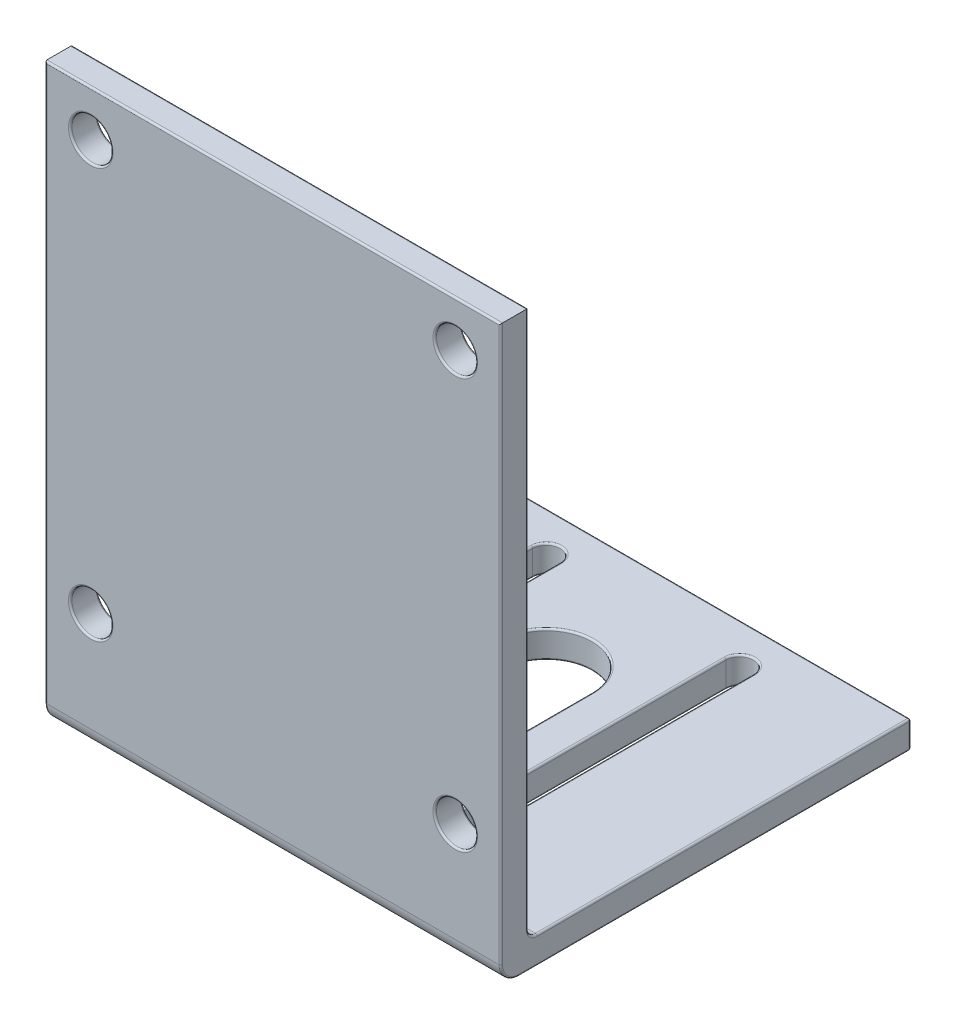
from build123d import *

# Parameters (mm, degrees)
SKETCH1_W           = 50
SKETCH1_H           = 45
BOSS_EXTRUDE1_DEPTH = 3
SKETCH2_W           = 50
SKETCH2_H           = 3
BOSS_EXTRUDE2_DEPTH = 60
SKETCH3_R           = 2.25
CUT_EXTRUDE1_DEPTH  = 60
FILLET1_R           = 1
FILLET2_R           = 2
FILLET3_R           = 0.2


with BuildPart() as part:
    # Sketch1 → Boss-Extrude1 (new body)
    with BuildSketch(Plane(origin=(0, 0, 0), x_dir=(1, 0, 0), z_dir=(0, 1, 0))):
        with Locations((0, 2.5)):
            Rectangle(SKETCH1_W, SKETCH1_H)
        with BuildLine():
            Line((12.108203194, 20.605), (12.108203194, -10.605))
            ThreePointArc((12.108203194, -10.605), (10.608203194, -12.105), (9.108203194, -10.605))
            Line((9.108203194, -10.605), (9.108203194, 20.605))
            ThreePointArc((9.108203194, 20.605), (10.608203194, 22.105), (12.108203194, 20.605))
        make_face(mode=Mode.SUBTRACT)
        with BuildLine():
            Line((-9.108203194, 20.605), (-9.108203194, -10.605))
            ThreePointArc((-9.108203194, -10.605), (-10.608203194, -12.105), (-12.108203194, -10.605))
            Line((-12.108203194, -10.605), (-12.108203194, 20.605))
            ThreePointArc((-12.108203194, 20.605), (-10.608203194, 22.105), (-9.108203194, 20.605))
        make_face(mode=Mode.SUBTRACT)
        with BuildLine():
            Line((-5, 0), (-5, 10))
            ThreePointArc((-5, 10), (0, 15), (5, 10))
            Line((5, 10), (5, 0))
            ThreePointArc((5, 0), (0, -5), (-5, 0))
        make_face(mode=Mode.SUBTRACT)
    extrude(amount=BOSS_EXTRUDE1_DEPTH)

    # Sketch2 → Boss-Extrude2 (add)
    with BuildSketch(Plane(origin=(0, 3, 0), x_dir=(1, 0, 0), z_dir=(0, 1, 0))):
        with Locations((0, -18.5)):
            Rectangle(SKETCH2_W, SKETCH2_H)
    extrude(amount=BOSS_EXTRUDE2_DEPTH)

    # Sketch3 → Cut-Extrude1 (cut)
    with BuildSketch(Plane(origin=(0, 0, 17), x_dir=(-1, 0, 0), z_dir=(0, 0, -1))):
        with Locations((20, 58)):
            Circle(SKETCH3_R)
        with Locations((-20, 58)):
            Circle(SKETCH3_R)
        with Locations((-20, 13)):
            Circle(SKETCH3_R)
        with Locations((20, 13)):
            Circle(SKETCH3_R)
    extrude(amount=-CUT_EXTRUDE1_DEPTH, mode=Mode.SUBTRACT)

    # Fillet1
    fillet1_edges = [part.edges().sort_by_distance(p)[0] for p in [
        (0, 3, 17),
    ]]
    fillet(fillet1_edges, radius=FILLET1_R)

    # Fillet2
    fillet2_edges = [part.edges().sort_by_distance(p)[0] for p in [
        (0, 0, 20),
    ]]
    fillet(fillet2_edges, radius=FILLET2_R)

    # Fillet3
    fillet3_edges = [part.edges().sort_by_distance(p)[0] for p in [
        (25, 0.585786438, 19.414213562),
        (-25, 0.585786438, 19.414213562),
        (10.608203194, 3, -22.105),
        (12.108203194, 3, -5),
        (25, 0, -3.5),
        (-25, 0, -3.5),
        (0, 0, -25),
        (5, 0, -5),
        (0, 0, -15),
        (-5, 0, -5),
        (0, 0, 5),
        (-10.608203194, 0, 12.105),
        (-9.108203194, 0, -5),
        (10.608203194, 3, 12.105),
        (-10.608203194, 0, -22.105),
        (-12.108203194, 0, -5),
        (10.608203194, 0, 12.105),
        (12.108203194, 0, -5),
        (10.608203194, 0, -22.105),
        (9.108203194, 0, -5),
        (-12.108203194, 3, -5),
        (25, 1.5, -25),
        (25, 32.5, 20),
        (-25, 32.5, 20),
        (-25, 1.5, -25),
        (-10.608203194, 3, -22.105),
        (-9.108203194, 3, -5),
        (-10.608203194, 3, 12.105),
        (0, 3, 5),
        (-25, 33.5, 17),
        (25, 33.5, 17),
        (0, 63, 20),
        (-5, 3, -5),
        (0, 63, 17),
        (0, 3, -15),
        (5, 3, -5),
        (-17.75, 13, 20),
        (-17.75, 13, 17),
        (0, 3, -25),
        (22.25, 13, 20),
        (22.25, 13, 17),
        (22.25, 58, 20),
        (22.25, 58, 17),
        (-25, 3, -4.5),
        (-17.75, 58, 20),
        (-17.75, 58, 17),
        (9.108203194, 3, -5),
        (25, 3, -4.5),
        (-25, 3.292893219, 16.707106781),
        (25, 3.292893219, 16.707106781),
    ]]
    fillet(fillet3_edges, radius=FILLET3_R)


solid = part.part
